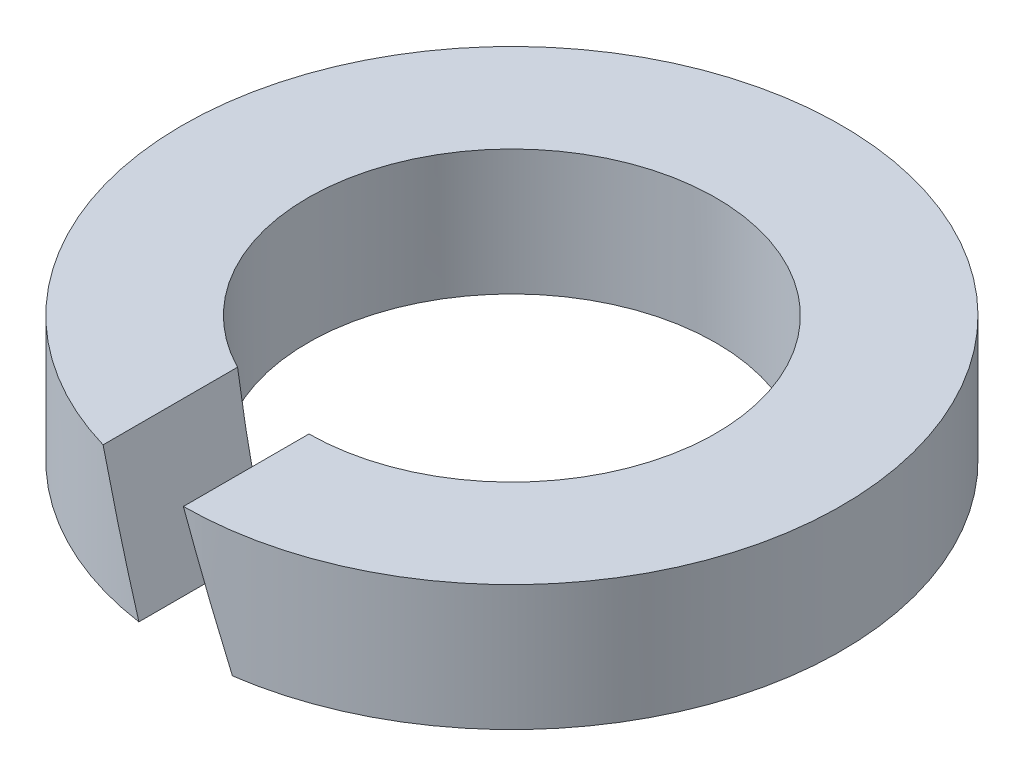
from build123d import *

# Parameters (mm, degrees)
SKE_W     = 0.8
SKE_H     = 0.8
CUT_REACH = 4.1


with BuildPart() as part:
    # Ske → Base (revolve)
    with BuildSketch(Plane.XY):
        with Locations((-1.7, 0.4)):
            Rectangle(SKE_W, SKE_H)
    revolve(axis=Axis((0, 15.759672306, 0), (0, -1, 0)))

    # Ske4 → Cut (cut, up to next)
    with BuildSketch(Plane.XY, mode=Mode.PRIVATE) as cut_sk1:
        Polygon((-0.297969776, 0), (0.297969776, 0), (0.006793589, 0.8), (-0.589145964, 0.8), align=None)
    cut_tool1 = extrude(cut_sk1.sketch, amount=CUT_REACH, mode=Mode.PRIVATE) & part.part
    add(cut_tool1.solids().sort_by_distance((-0.145588, 0.4, 0))[0], mode=Mode.SUBTRACT)


solid = part.part
